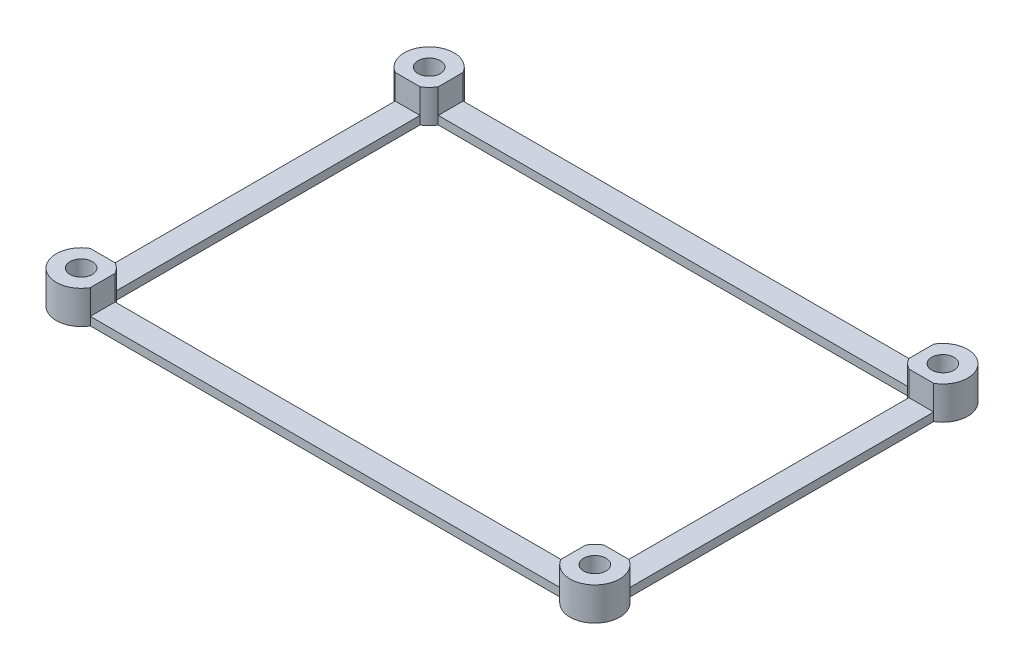
from build123d import *

# Parameters (mm, degrees)
SKETCH1_R           = 1.35
BOSS_EXTRUDE1_DEPTH = 4
SKETCH2_W           = 3
SKETCH2_H           = 36.803847578
SKETCH2_W_2         = 56.803847578
SKETCH2_H_2         = 3
CUT_EXTRUDE1_DEPTH  = 3


with BuildPart() as part:
    # Sketch1 → Boss-Extrude1 (new body)
    with BuildSketch(Plane(origin=(0, 0, 0), x_dir=(1, 0, 0), z_dir=(0, 1, 0))):
        with BuildLine():
            Line((-28.401923789, 22.5), (28.401923789, 22.5))
            ThreePointArc((28.401923789, 22.5), (33.121320344, 23.121320344), (32.5, 18.401923789))
            Line((32.5, 18.401923789), (32.5, -18.401923789))
            ThreePointArc((32.5, -18.401923789), (33.121320344, -23.121320344), (28.401923789, -22.5))
            Line((28.401923789, -22.5), (-28.401923789, -22.5))
            ThreePointArc((-28.401923789, -22.5), (-33.121320344, -23.121320344), (-32.5, -18.401923789))
            Line((-32.5, -18.401923789), (-32.5, 18.401923789))
            ThreePointArc((-32.5, 18.401923789), (-33.121320344, 23.121320344), (-28.401923789, 22.5))
        make_face()
        with Locations((31, 21)):
            Circle(SKETCH1_R, mode=Mode.SUBTRACT)
        with Locations((31, -21)):
            Circle(SKETCH1_R, mode=Mode.SUBTRACT)
        with Locations((-31, -21)):
            Circle(SKETCH1_R, mode=Mode.SUBTRACT)
        with Locations((-31, 21)):
            Circle(SKETCH1_R, mode=Mode.SUBTRACT)
        with BuildLine():
            Line((-28.401923789, 19.5), (28.401923789, 19.5))
            ThreePointArc((28.401923789, 19.5), (28.878679656, 18.878679656), (29.5, 18.401923789))
            Line((29.5, 18.401923789), (29.5, -18.401923789))
            ThreePointArc((29.5, -18.401923789), (28.878679656, -18.878679656), (28.401923789, -19.5))
            Line((28.401923789, -19.5), (-28.401923789, -19.5))
            ThreePointArc((-28.401923789, -19.5), (-28.878679656, -18.878679656), (-29.5, -18.401923789))
            Line((-29.5, -18.401923789), (-29.5, 18.401923789))
            ThreePointArc((-29.5, 18.401923789), (-28.878679656, 18.878679656), (-28.401923789, 19.5))
        make_face(mode=Mode.SUBTRACT)
    extrude(amount=BOSS_EXTRUDE1_DEPTH)

    # Sketch2 → Cut-Extrude1 (cut)
    with BuildSketch(Plane(origin=(0, 4, 0), x_dir=(1, 0, 0), z_dir=(0, 1, 0))):
        with Locations((-31, 0)):
            Rectangle(SKETCH2_W, SKETCH2_H)
        with Locations((0, -21)):
            Rectangle(SKETCH2_W_2, SKETCH2_H_2)
        with Locations((31, 0)):
            Rectangle(SKETCH2_W, SKETCH2_H)
        with Locations((0, 21)):
            Rectangle(SKETCH2_W_2, SKETCH2_H_2)
    extrude(amount=-CUT_EXTRUDE1_DEPTH, mode=Mode.SUBTRACT)


solid = part.part
